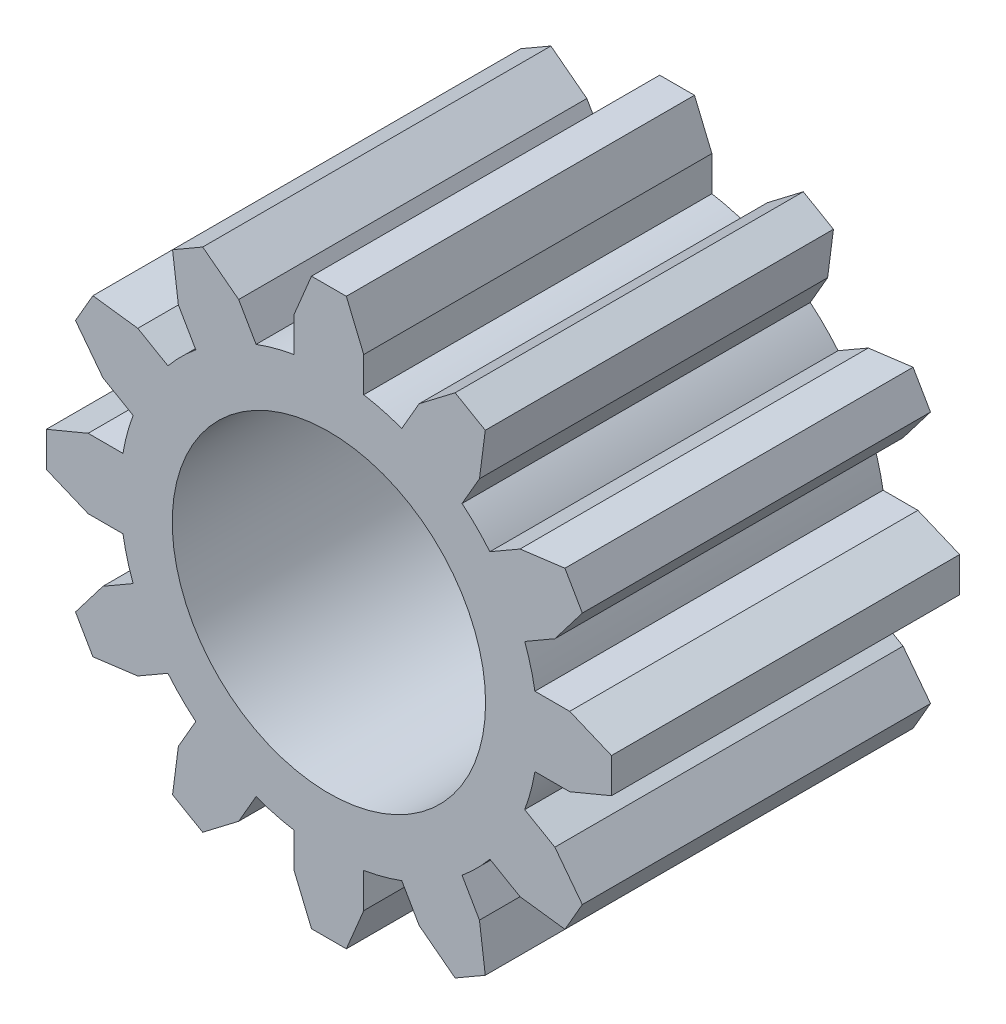
from build123d import *

# Parameters (mm, degrees)
SKETCH1_R           = 4.5
BOSS_EXTRUDE1_DEPTH = 5
CIRPATTERN1_COUNT   = 12


with BuildPart() as part:
    # Sketch1 → Boss-Extrude1 (new body, symmetric)
    with BuildSketch(Plane.XY):
        with BuildLine():
            Line((-1, 6.916079783), (-1, 5.916079783))
            ThreePointArc((-1, 5.916079783), (0, -6), (1, 5.916079783))
            Line((1, 5.916079783), (1, 6.916079783))
            Line((1, 6.916079783), (0.5, 8.116079783))
            Line((0.5, 8.116079783), (-0.5, 8.116079783))
            Line((-0.5, 8.116079783), (-1, 6.916079783))
        make_face()
        Circle(SKETCH1_R, mode=Mode.SUBTRACT)
    boss_extrude1 = extrude(amount=BOSS_EXTRUDE1_DEPTH, both=True)

    # CirPattern1: Boss-Extrude1 ×12 about axis
    cirpattern1_axis = Axis((0, 0, 0), (0, 0, 1))
    for i in range(1, CIRPATTERN1_COUNT):
        add(boss_extrude1.rotate(cirpattern1_axis, i * 360 / CIRPATTERN1_COUNT))


solid = part.part
